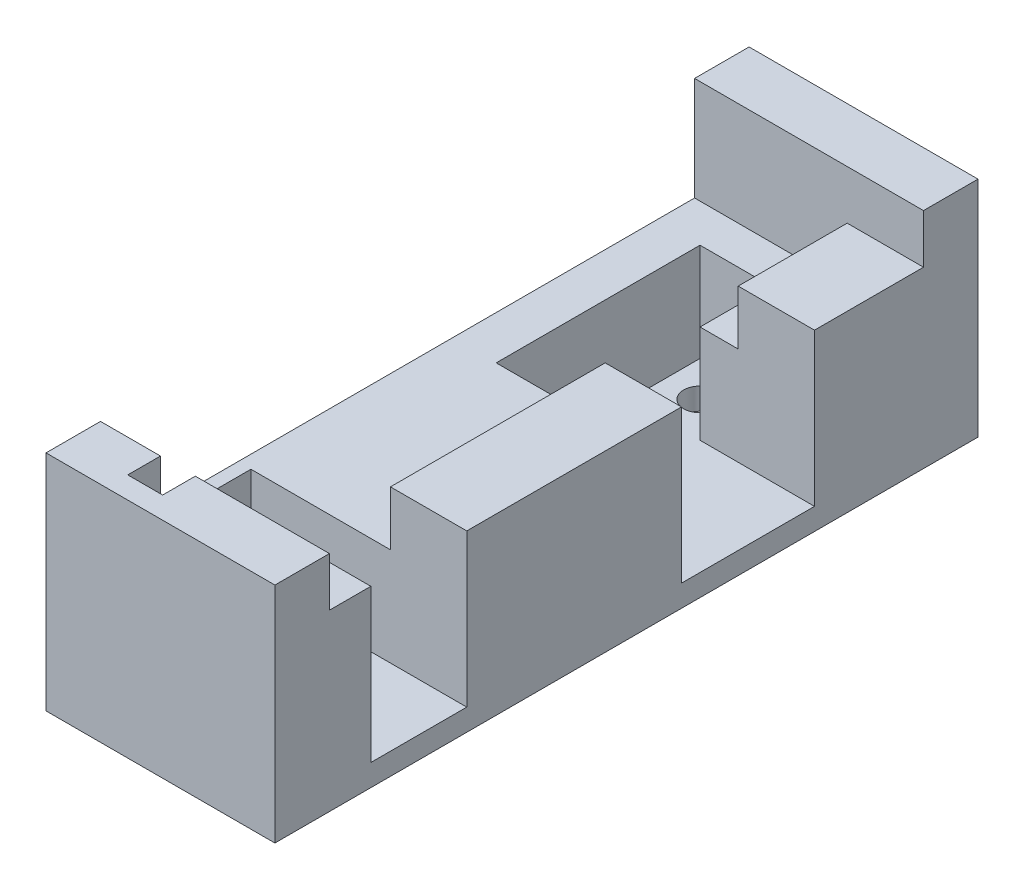
from build123d import *

# Parameters (mm, degrees)
BOSS_EXTRUDE2_DEPTH = 14
SKETCH3_W           = 21
SKETCH3_H           = 54.5
SKETCH3_R           = 1.5
BOSS_EXTRUDE3_DEPTH = 2
SKETCH4_W           = 14
SKETCH4_H           = 54.5
CUT_EXTRUDE1_DEPTH  = 5
BOSS_EXTRUDE4_DEPTH = 5
BOSS_EXTRUDE6_DEPTH = 5
BOSS_EXTRUDE7_REACH = 10.7
SKETCH8_W           = 2
SKETCH8_H           = 4.5


with BuildPart() as part:
    # Sketch1 → Boss-Extrude2 (new body)
    with BuildSketch(Plane(origin=(0, 0, 0), x_dir=(1, 0, 0), z_dir=(0, 1, 0))):
        Polygon((0, 0), (-7, 0), (-21, 0), (-21, -54.5), (-13.577905098, -54.5), (0, -54.5), (0, -50.7), (-5.8, -50.7), (-19.8, -50.7), (-19.8, -41.9), (-5.8, -41.9), (0, -41.9), (0, -22.2), (-17, -22.2), (-17, -10), (-17, -3.5), (-10.5, -3.5), (-10.5, -10), (0, -10), align=None)
    extrude(amount=BOSS_EXTRUDE2_DEPTH)

    # Sketch3 → Boss-Extrude3 (add)
    with BuildSketch(Plane(origin=(0, 0, 0), x_dir=(1, 0, 0), z_dir=(0, 1, 0))):
        with Locations((-10.5, -27.25)):
            Rectangle(SKETCH3_W, SKETCH3_H)
        with Locations((-13.75, -6.75)):
            Circle(SKETCH3_R, mode=Mode.SUBTRACT)
    extrude(amount=-BOSS_EXTRUDE3_DEPTH)

    # Sketch4 → Cut-Extrude1 (cut)
    with BuildSketch(Plane(origin=(0, 14, 0), x_dir=(1, 0, 0), z_dir=(0, 1, 0))):
        with Locations((-14, -27.25)):
            Rectangle(SKETCH4_W, SKETCH4_H)
    extrude(amount=-CUT_EXTRUDE1_DEPTH, mode=Mode.SUBTRACT)

    # Sketch5 → Boss-Extrude4 (add)
    with BuildSketch(Plane.XY.offset(54.5)):
        Polygon((-12.3, -2), (0, -2), (0, 14), (-7, 14), (-7, 9), (-21, 9), (-21, -2), (-15.5, -2), align=None)
        Polygon((-7, 14), (0, 14), (0, 18.5), (-12.3, 18.5), (-12.3, 14), (-15.5, 14), (-15.5, 18.5), (-21, 18.5), (-21, 9), (-7, 9), align=None)
    extrude(amount=BOSS_EXTRUDE4_DEPTH)

    # Sketch7 → Boss-Extrude6 (add)
    with BuildSketch(Plane(origin=(0, 0, 0), x_dir=(-1, 0, 0), z_dir=(0, 0, -1))):
        Polygon((0, 18.5), (12.3, 18.5), (21, 18.5), (21, -2), (0, -2), align=None)
    extrude(amount=BOSS_EXTRUDE6_DEPTH)

    # Sketch8 → Boss-Extrude7 (add, up to next)
    with BuildSketch(Plane.ZY.offset(12.3), mode=Mode.PRIVATE) as boss_extrude7_sk1:
        with Locations((58.5, 16.25)):
            Rectangle(SKETCH8_W, SKETCH8_H)
    boss_extrude7_tool1 = extrude(boss_extrude7_sk1.sketch, amount=BOSS_EXTRUDE7_REACH, mode=Mode.PRIVATE) - part.part
    add(boss_extrude7_tool1.solids().sort_by_distance((-12.3, 16.25, 58.5))[0])


solid = part.part
